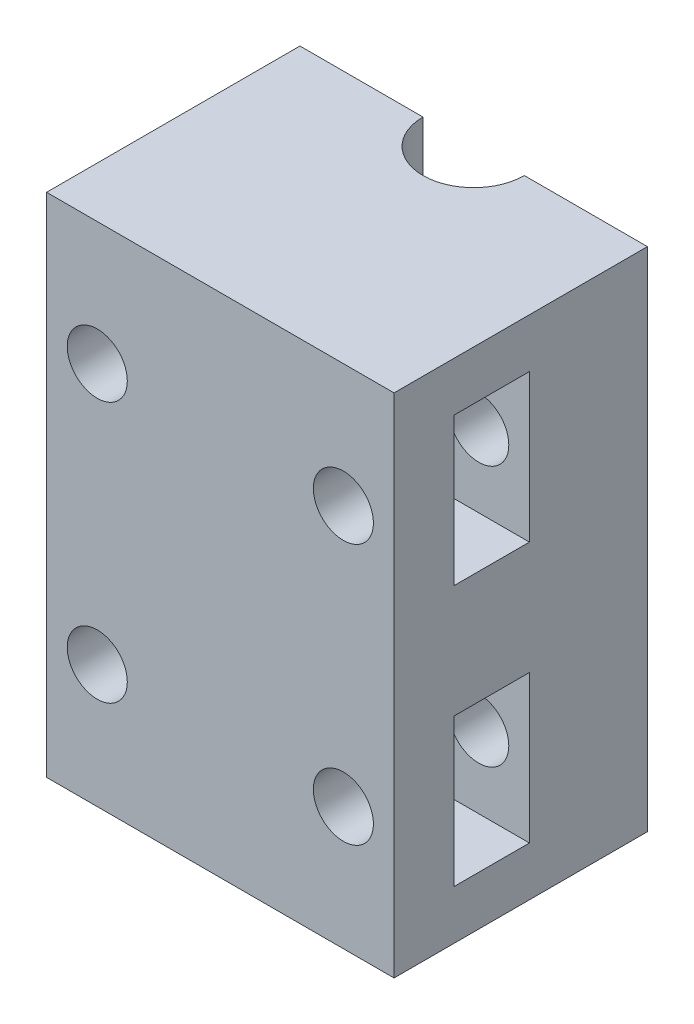
from build123d import *

# Parameters (mm, degrees)
SKETCH1_W               = 48
SKETCH1_H               = 35
BOSS_EXTRUDE1_DEPTH     = 70
SKETCH2_W               = 10.4
SKETCH2_H               = 20.4
CUT_EXTRUDE1_DEPTH      = 45
SKETCH3_R               = 4.15
CUT_EXTRUDE2_DEPTH      = 36
CUT_EXTRUDE3_DEPTH      = 1
CUT_EXTRUDE3_DEPTH_BACK = 71


with BuildPart() as part:
    # Sketch1 → Boss-Extrude1 (new body)
    with BuildSketch(Plane(origin=(0, 0, 0), x_dir=(1, 0, 0), z_dir=(0, 1, 0))):
        Rectangle(SKETCH1_W, SKETCH1_H)
    extrude(amount=BOSS_EXTRUDE1_DEPTH)

    # Sketch2 → Cut-Extrude1 (cut)
    with BuildSketch(Plane(origin=(24, 0, 0), x_dir=(0, 0, -1), z_dir=(1, 0, 0))):
        with Locations((-4, 53)):
            Rectangle(SKETCH2_W, SKETCH2_H)
        with Locations((-4, 17)):
            Rectangle(SKETCH2_W, SKETCH2_H)
    extrude(amount=-CUT_EXTRUDE1_DEPTH, mode=Mode.SUBTRACT)

    # Sketch3 → Cut-Extrude2 (cut, through all)
    with BuildSketch(Plane.XY.offset(17.5)):
        with Locations((17, 53)):
            Circle(SKETCH3_R)
        with Locations((-17, 53)):
            Circle(SKETCH3_R)
        with Locations((-17, 17)):
            Circle(SKETCH3_R)
        with Locations((17, 17)):
            Circle(SKETCH3_R)
    extrude(amount=-CUT_EXTRUDE2_DEPTH, mode=Mode.SUBTRACT)

    # Sketch4 → Cut-Extrude3 (cut, two sides)
    with BuildSketch(Plane(origin=(0, 70, 0), x_dir=(1, 0, 0), z_dir=(0, 1, 0))) as cut_extrude3_sk:
        with BuildLine():
            Line((-7, 121.00935782), (-7, 17.5))
            ThreePointArc((-7, 17.5), (0, 10.5), (7, 17.5))
            Line((7, 17.5), (7, 121.00935782))
            Line((7, 121.00935782), (7, 328.028073461))
            Line((7, 328.028073461), (-7, 328.028073461))
            Line((-7, 328.028073461), (-7, 121.00935782))
        make_face()
    extrude(amount=CUT_EXTRUDE3_DEPTH, mode=Mode.SUBTRACT)
    extrude(cut_extrude3_sk.sketch, amount=-CUT_EXTRUDE3_DEPTH_BACK, mode=Mode.SUBTRACT)


solid = part.part
